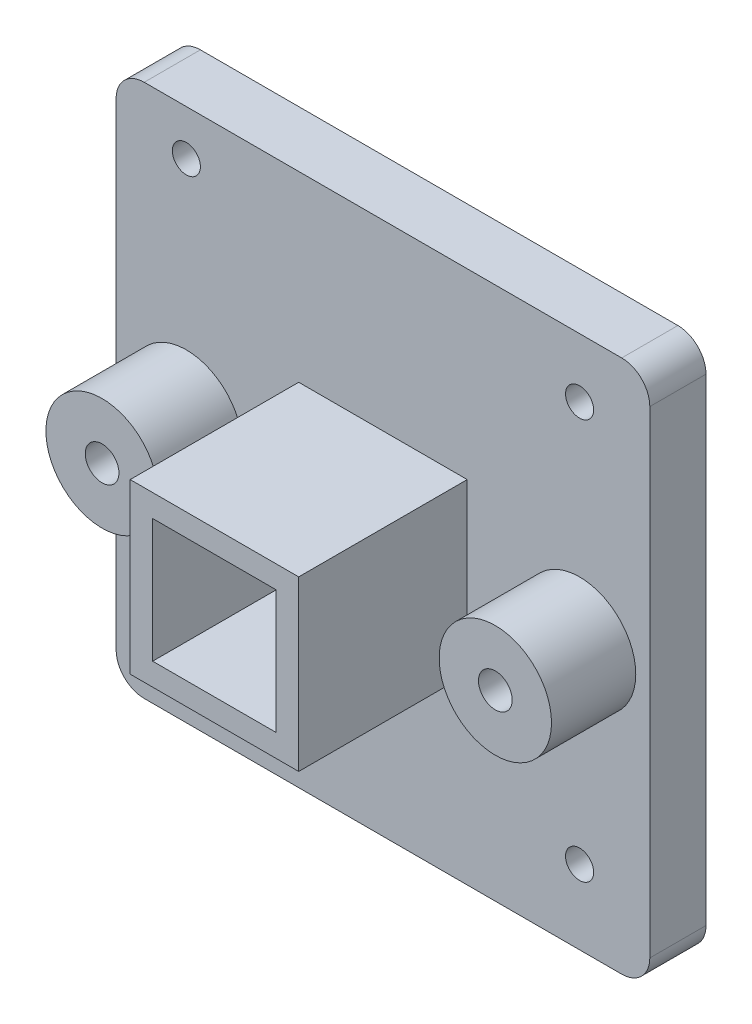
from build123d import *

# Parameters (mm, degrees)
SKETCH1_W           = 190
SKETCH1_H           = 190
SKETCH1_R           = 20
SKETCH1_R_2         = 5
SKETCH1_W_2         = 44
SKETCH1_H_2         = 44
BOSS_EXTRUDE2_DEPTH = 20
SKETCH2_R           = 20
SKETCH2_R_2         = 6
BOSS_EXTRUDE5_DEPTH = 50
SKETCH4_R           = 20
BOSS_EXTRUDE6_DEPTH = 3
FILLET1_R           = 10
SKETCH6_W           = 60
SKETCH6_H           = 60
SKETCH6_W_2         = 44
SKETCH6_H_2         = 44
BOSS_EXTRUDE7_DEPTH = 80


with BuildPart() as part:
    # Sketch1 → Boss-Extrude2 (new body)
    with BuildSketch(Plane.XY):
        Rectangle(SKETCH1_W, SKETCH1_H)
        with Locations((-70, 0)):
            Circle(SKETCH1_R, mode=Mode.SUBTRACT)
        with Locations((70, 0)):
            Circle(SKETCH1_R, mode=Mode.SUBTRACT)
        with Locations((70, -68.596885854)):
            Circle(SKETCH1_R_2, mode=Mode.SUBTRACT)
        with Locations((-70, -73.596885854)):
            Circle(SKETCH1_R_2, mode=Mode.SUBTRACT)
        with Locations((70, 73.936439664)):
            Circle(SKETCH1_R_2, mode=Mode.SUBTRACT)
        with Locations((-70, 78.936439664)):
            Circle(SKETCH1_R_2, mode=Mode.SUBTRACT)
        Rectangle(SKETCH1_W_2, SKETCH1_H_2, mode=Mode.SUBTRACT)
    extrude(amount=BOSS_EXTRUDE2_DEPTH)

    # Sketch2 → Boss-Extrude5 (add)
    with BuildSketch(Plane.XY):
        with Locations((-70, 0)):
            Circle(SKETCH2_R)
        with Locations((-70, 0)):
            Circle(SKETCH2_R_2, mode=Mode.SUBTRACT)
        with Locations((70, 0)):
            Circle(SKETCH2_R)
        with Locations((70, 0)):
            Circle(SKETCH2_R_2, mode=Mode.SUBTRACT)
    extrude(amount=BOSS_EXTRUDE5_DEPTH)

    # Sketch4 → Boss-Extrude6 (add)
    with BuildSketch(Plane.XY):
        with Locations((70, 0)):
            Circle(SKETCH4_R)
        with Locations((-70, 0)):
            Circle(SKETCH4_R)
    extrude(amount=BOSS_EXTRUDE6_DEPTH)

    # Fillet1
    fillet1_edges = [part.edges().sort_by_distance(p)[0] for p in [
        (95, -95, 10),
        (-95, -95, 10),
        (-95, 95, 10),
        (95, 95, 10),
    ]]
    fillet(fillet1_edges, radius=FILLET1_R)

    # Sketch6 → Boss-Extrude7 (add)
    with BuildSketch(Plane.XY):
        Rectangle(SKETCH6_W, SKETCH6_H)
        Rectangle(SKETCH6_W_2, SKETCH6_H_2, mode=Mode.SUBTRACT)
    extrude(amount=BOSS_EXTRUDE7_DEPTH)


solid = part.part
